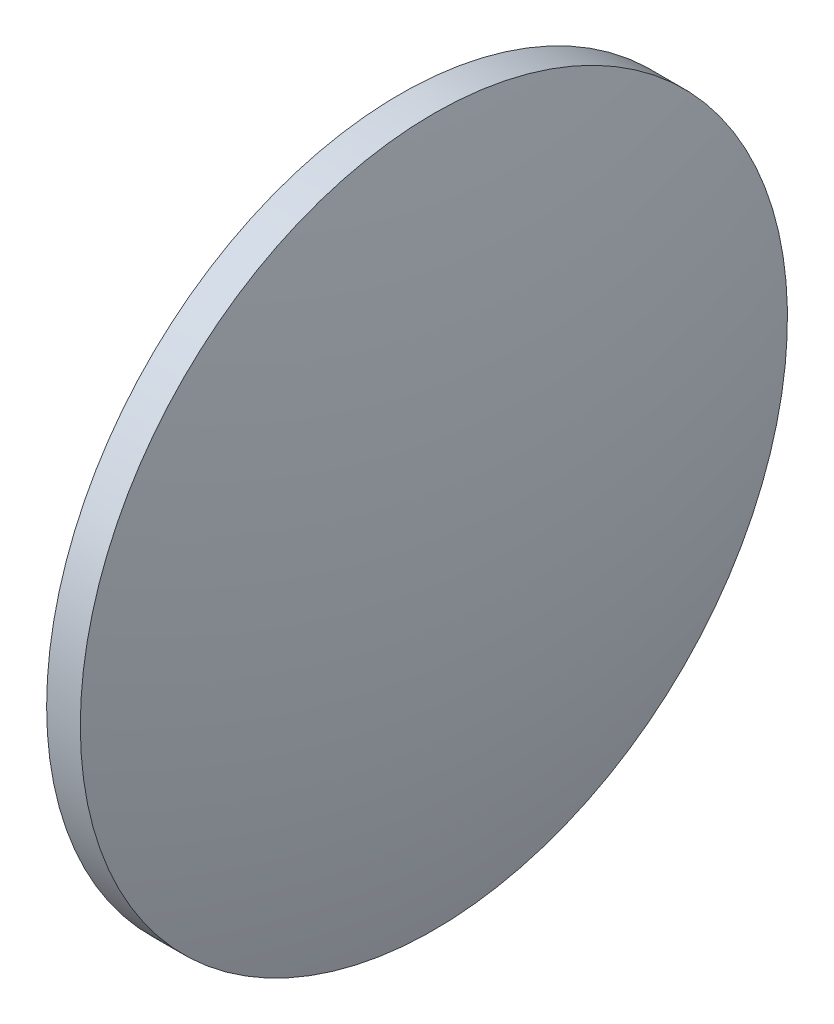
from build123d import *


with BuildPart() as part:
    # 草图1 → 旋转1 (revolve)
    with BuildSketch(Plane.XY):
        with BuildLine():
            Line((467.101655019, 57.89546231), (467.101655019, 89.39546231))
            Line((467.101655019, 89.39546231), (470.101655019, 89.39546231))
            ThreePointArc((470.101655019, 89.39546231), (473.02294699, 73.765717507), (474.001655019, 57.89546231))
            Line((474.001655019, 57.89546231), (467.101655019, 57.89546231))
        make_face()
    revolve(axis=Axis((458.332020755, 57.89546231, 0), (1, 0, 0)))


solid = part.part
